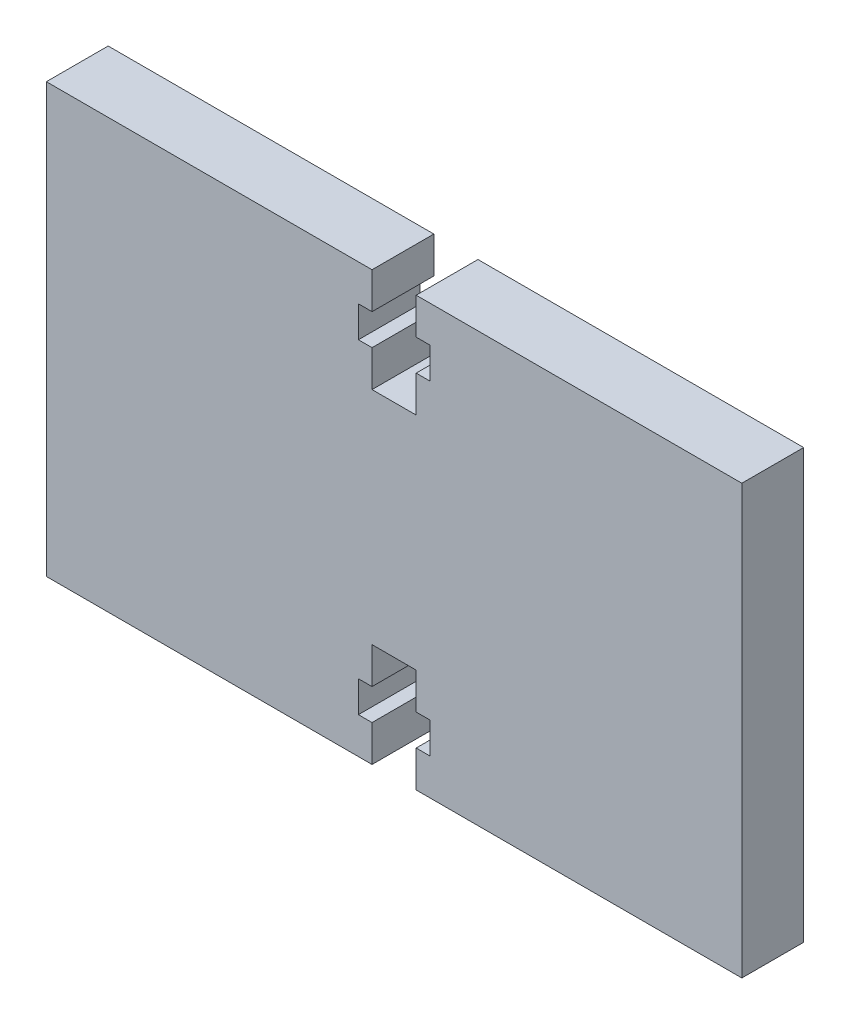
from build123d import *

# Parameters (mm, degrees)
BOSS_EXTRUDE1_DEPTH = 4.7625


with BuildPart() as part:
    # Sketch1 → Boss-Extrude1 (new body)
    with BuildSketch(Plane.XY):
        Polygon((1.7, -16.51), (1.7, -13.71), (2.75, -13.71), (2.75, -11.31), (1.7, -11.31), (1.7, -8.51), (-1.7, -8.51), (-1.7, -11.31), (-2.75, -11.31), (-2.75, -13.71), (-1.7, -13.71), (-1.7, -16.51), (-26.797, -16.51), (-26.797, 16.51), (-1.7, 16.51), (-1.7, 13.71), (-2.75, 13.71), (-2.75, 11.31), (-1.7, 11.31), (-1.7, 8.51), (1.7, 8.51), (1.7, 11.31), (2.75, 11.31), (2.75, 13.71), (1.7, 13.71), (1.7, 16.51), (26.797, 16.51), (26.797, -16.51), align=None)
    extrude(amount=BOSS_EXTRUDE1_DEPTH)


solid = part.part
